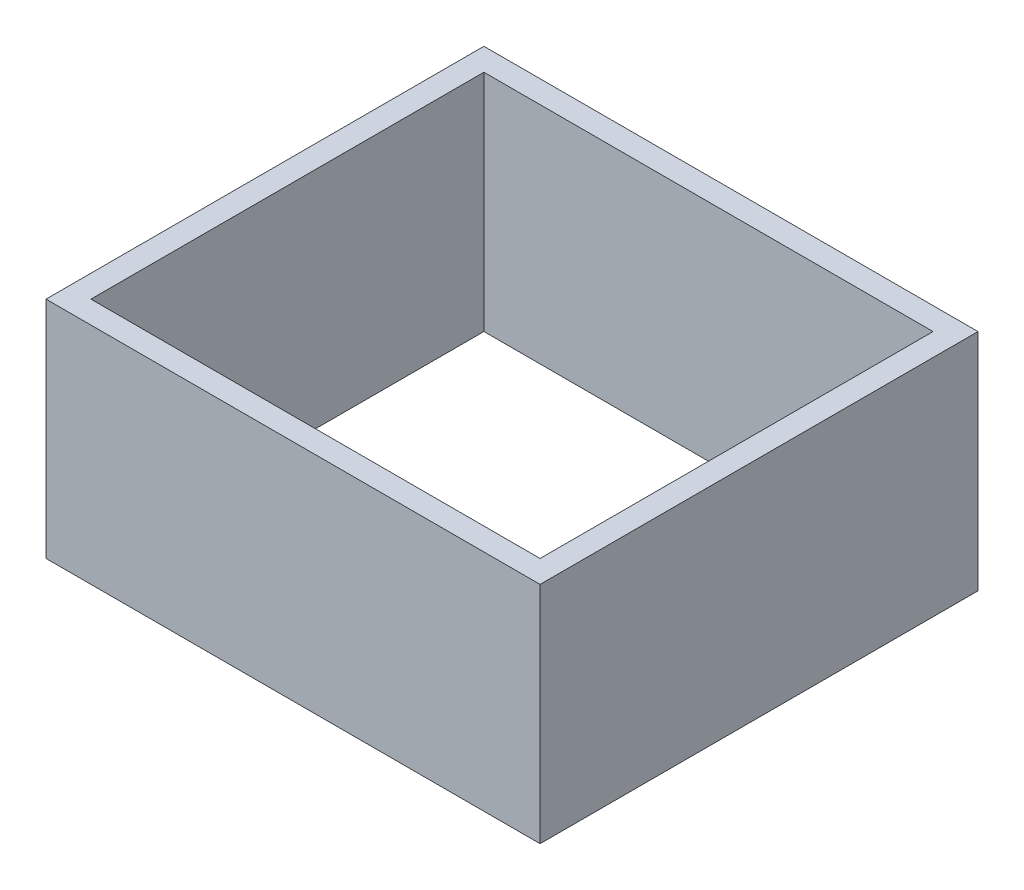
from build123d import *

# Parameters (mm, degrees)
SKETCH1_W           = 55.88
SKETCH1_H           = 49.53
BOSS_EXTRUDE1_DEPTH = 25.4
SKETCH2_W           = 50.8
SKETCH2_H           = 44.45
CUT_EXTRUDE1_DEPTH  = 25.4


with BuildPart() as part:
    # Sketch1 → Boss-Extrude1 (new body)
    with BuildSketch(Plane(origin=(0, 0, 0), x_dir=(1, 0, 0), z_dir=(0, 1, 0))):
        with Locations((-3.034932129, 10.85764574)):
            Rectangle(SKETCH1_W, SKETCH1_H)
    extrude(amount=BOSS_EXTRUDE1_DEPTH)

    # Sketch2 → Cut-Extrude1 (cut)
    with BuildSketch(Plane(origin=(0, 25.4, 0), x_dir=(1, 0, 0), z_dir=(0, 1, 0))):
        with Locations((-3.034932129, 10.85764574)):
            Rectangle(SKETCH2_W, SKETCH2_H)
    extrude(amount=-CUT_EXTRUDE1_DEPTH, mode=Mode.SUBTRACT)


solid = part.part
